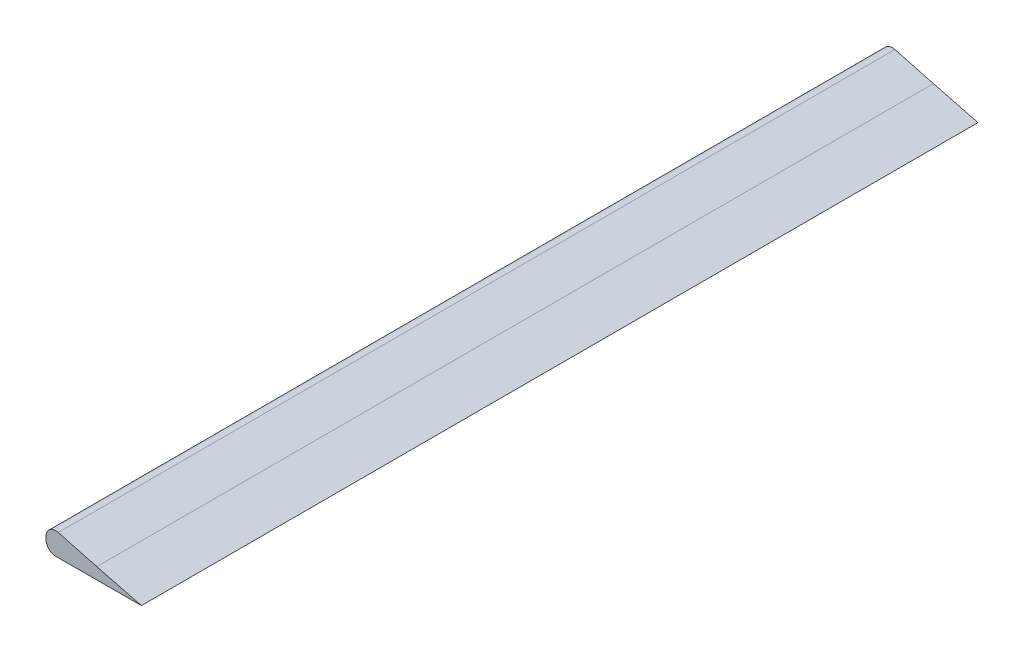
from build123d import *

# Parameters (mm, degrees)
BOSS_EXTRUDE1_DEPTH = 297
SKETCH2_W           = 12
SKETCH2_H           = 12
CUT_EXTRUDE1_DEPTH  = 4.945151286


with BuildPart() as part:
    # Sketch1 → Boss-Extrude1 (new body)
    with BuildSketch(Plane.XY):
        with BuildLine():
            Line((-16.507687929, 2.364265208), (-16.507687929, 1.473962835))
            ThreePointArc((-16.507687929, 1.473962835), (-15.480371114, -1.003099511), (-13.001494862, -2.026031686))
            add(Edge.make_bspline(
                [(-13.001494862, -2.026031686), (-8.333069772, -2.017771139), (-3.664620889, -2.009483171), (1.003807611, -2.000595376)],
                knots=[0.953389627, 0.953389627, 0.953389627, 0.953389627, 1, 1, 1, 1], degree=3))
            add(Edge.make_bspline(
                [(1.003807611, -2.000595376), (6.455319533, -1.990216739), (11.906803659, -1.979020166), (17.35818964, -1.966094188)],
                knots=[1, 1, 1, 1, 1.054428809, 1.054428809, 1.054428809, 1.054428809], degree=3))
            Line((17.35818964, -1.966094188), (1.535215778, 2.104151955))
            add(Edge.make_bspline(
                [(1.535215778, 2.104151955), (-1.489505662, 2.933853479), (-6.037640577, 4.177264079), (-10.60829151, 5.363992379), (-12.14197353, 5.755509607)],
                knots=[0, 0, 0, 0, 0.03125, 0.04700086, 0.04700086, 0.04700086, 0.04700086], degree=3))
            ThreePointArc((-12.14197353, 5.755509607), (-15.154778938, 5.128320236), (-16.507687929, 2.364265208))
        make_face()
    extrude(amount=BOSS_EXTRUDE1_DEPTH)

    # Sketch2 → Cut-Extrude1 (cut, through all)
    with BuildSketch(Plane.XZ.offset(-1.919114021)):
        with Locations((-10.507687929, 242)):
            Rectangle(SKETCH2_W, SKETCH2_H)
        with Locations((-10.507687929, 55)):
            Rectangle(SKETCH2_W, SKETCH2_H)
    extrude(amount=CUT_EXTRUDE1_DEPTH, mode=Mode.SUBTRACT)


solid = part.part
